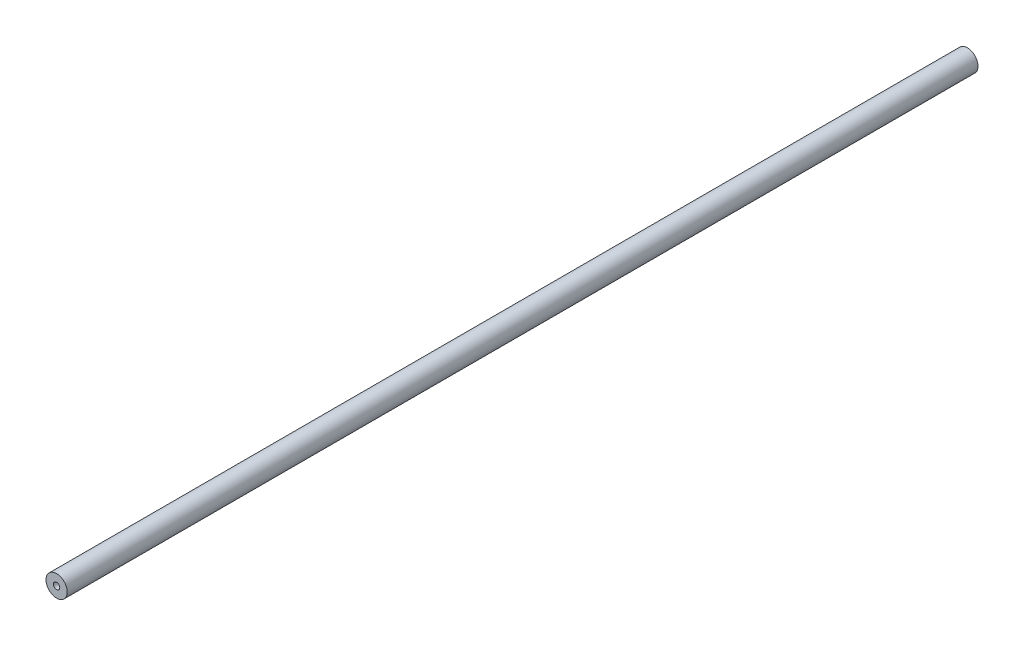
from build123d import *

# Parameters (mm, degrees)
SKETCH1_R                  = 6.4
BOSS_EXTRUDE1_DEPTH        = 548.24
F_10_24_TAPPED_HOLE1_D     = 3.7973
F_10_24_TAPPED_HOLE1_DEPTH = 12.83
F_10_24_TAPPED_HOLE1_TIP   = 1.140824014
F_10_24_TAPPED_HOLE2_D     = 3.7973
F_10_24_TAPPED_HOLE2_DEPTH = 12.83
F_10_24_TAPPED_HOLE2_TIP   = 1.140824014


with BuildPart() as part:
    # Sketch1 → Boss-Extrude1 (new body)
    with BuildSketch(Plane.XY):
        Circle(SKETCH1_R)
    extrude(amount=BOSS_EXTRUDE1_DEPTH)

    # #10-24 Tapped Hole1
    with Locations(Plane(origin=(0, 0, 0), x_dir=(-1, 0, 0), z_dir=(0, 0, -1))):
        with Locations((0, 0)):
            Hole(F_10_24_TAPPED_HOLE1_D / 2, depth=F_10_24_TAPPED_HOLE1_DEPTH)
            with Locations((0, 0, -(F_10_24_TAPPED_HOLE1_DEPTH + F_10_24_TAPPED_HOLE1_TIP / 2))):  # 118° drill point
                Cone(0, F_10_24_TAPPED_HOLE1_D / 2, F_10_24_TAPPED_HOLE1_TIP, mode=Mode.SUBTRACT)

    # #10-24 Tapped Hole2
    with Locations(Plane.XY.offset(548.24)):
        with Locations((0, 0)):
            Hole(F_10_24_TAPPED_HOLE2_D / 2, depth=F_10_24_TAPPED_HOLE2_DEPTH)
            with Locations((0, 0, -(F_10_24_TAPPED_HOLE2_DEPTH + F_10_24_TAPPED_HOLE2_TIP / 2))):  # 118° drill point
                Cone(0, F_10_24_TAPPED_HOLE2_D / 2, F_10_24_TAPPED_HOLE2_TIP, mode=Mode.SUBTRACT)


solid = part.part
